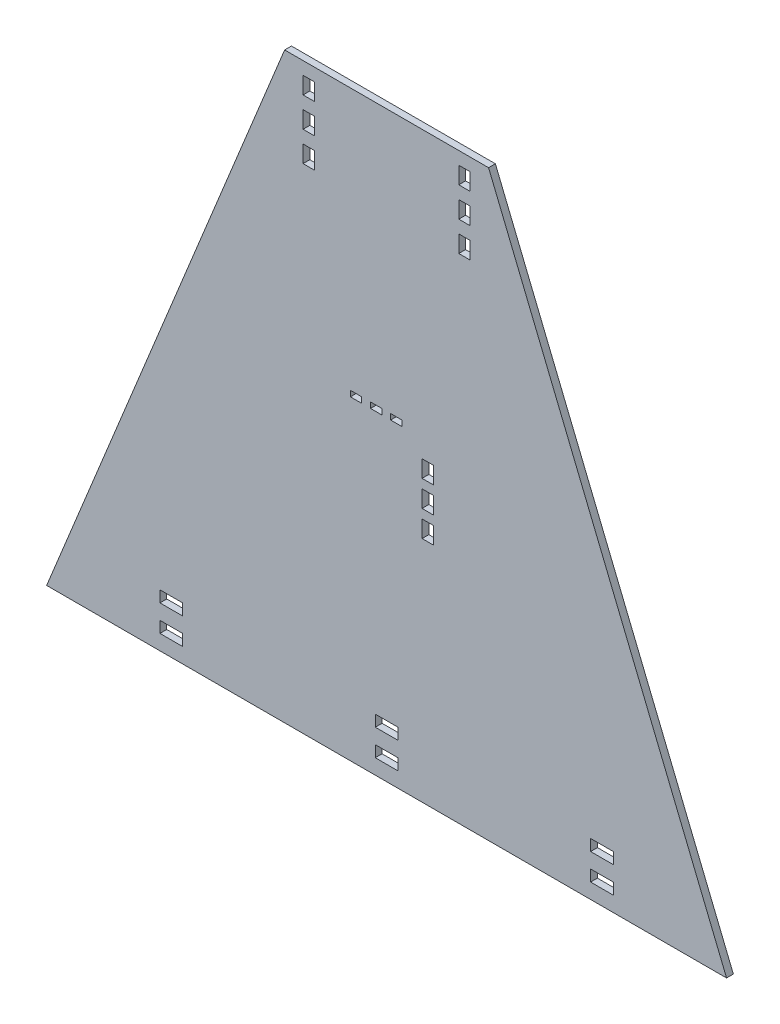
from build123d import *

# Parameters (mm, degrees)
SKETCH1_W           = 20
SKETCH1_H           = 10
SKETCH1_W_2         = 10
SKETCH1_H_2         = 5
SKETCH1_H_3         = 15
BOSS_EXTRUDE1_DEPTH = 6


with BuildPart() as part:
    # Sketch1 → Boss-Extrude1 (new body)
    with BuildSketch(Plane.XY):
        Polygon((296.475, 0), (0, 0), (210.025, 514.3036198), (390.025, 514.3036198), (600.05, 0), (300.025, 0), align=None)
        with Locations((110, 18.333333333)):
            Rectangle(SKETCH1_W, SKETCH1_H, mode=Mode.SUBTRACT)
        with Locations((110, 41.666666667)):
            Rectangle(SKETCH1_W, SKETCH1_H, mode=Mode.SUBTRACT)
        with Locations((490.05, 41.666666667)):
            Rectangle(SKETCH1_W, SKETCH1_H, mode=Mode.SUBTRACT)
        with Locations((490.05, 18.333333333)):
            Rectangle(SKETCH1_W, SKETCH1_H, mode=Mode.SUBTRACT)
        with Locations((308.575, 280.6998099)):
            Rectangle(SKETCH1_W_2, SKETCH1_H_2, mode=Mode.SUBTRACT)
        with Locations((290.825, 280.6998099)):
            Rectangle(SKETCH1_W_2, SKETCH1_H_2, mode=Mode.SUBTRACT)
        with Locations((273.075, 280.6998099)):
            Rectangle(SKETCH1_W_2, SKETCH1_H_2, mode=Mode.SUBTRACT)
        with Locations((368.725, 495.5536198)):
            Rectangle(SKETCH1_W_2, SKETCH1_H_3, mode=Mode.SUBTRACT)
        with Locations((368.725, 469.3036198)):
            Rectangle(SKETCH1_W_2, SKETCH1_H_3, mode=Mode.SUBTRACT)
        with Locations((336.325, 255.0068099)):
            Rectangle(SKETCH1_W_2, SKETCH1_H_3, mode=Mode.SUBTRACT)
        with Locations((336.325, 232.0068099)):
            Rectangle(SKETCH1_W_2, SKETCH1_H_3, mode=Mode.SUBTRACT)
        with Locations((336.325, 209.0068099)):
            Rectangle(SKETCH1_W_2, SKETCH1_H_3, mode=Mode.SUBTRACT)
        with Locations((368.725, 443.0536198)):
            Rectangle(SKETCH1_W_2, SKETCH1_H_3, mode=Mode.SUBTRACT)
        with Locations((231.325, 443.0536198)):
            Rectangle(SKETCH1_W_2, SKETCH1_H_3, mode=Mode.SUBTRACT)
        with Locations((231.325, 469.3036198)):
            Rectangle(SKETCH1_W_2, SKETCH1_H_3, mode=Mode.SUBTRACT)
        with Locations((231.325, 495.5536198)):
            Rectangle(SKETCH1_W_2, SKETCH1_H_3, mode=Mode.SUBTRACT)
        with Locations((300.025, 41.666666667)):
            Rectangle(SKETCH1_W, SKETCH1_H, mode=Mode.SUBTRACT)
        with Locations((300.025, 18.333333333)):
            Rectangle(SKETCH1_W, SKETCH1_H, mode=Mode.SUBTRACT)
    extrude(amount=BOSS_EXTRUDE1_DEPTH)


solid = part.part
